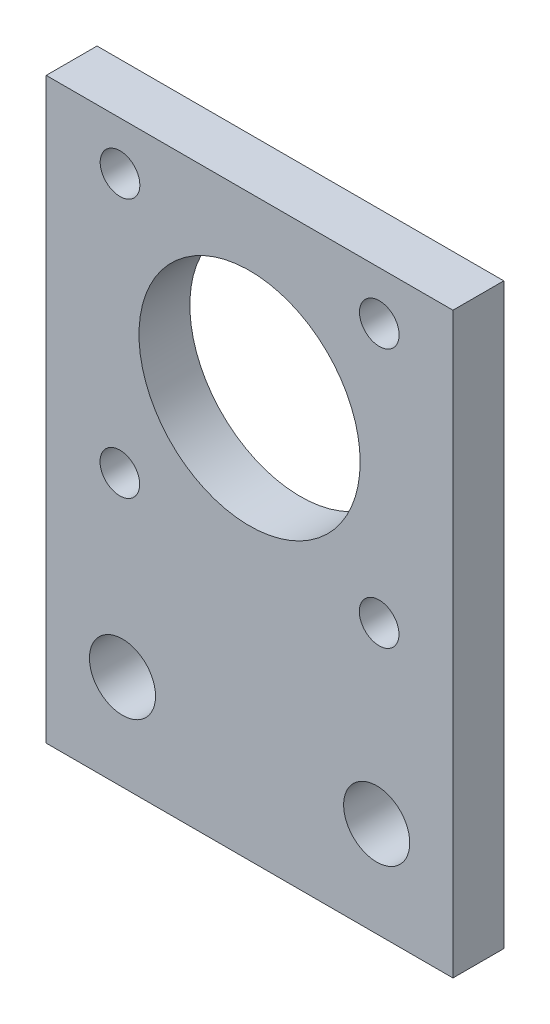
from build123d import *

# Parameters (mm, degrees)
SKETCH1_W           = 40.64
SKETCH1_H           = 19.05
SKETCH1_R           = 3.302
SKETCH1_H_2         = 38.735
SKETCH1_R_2         = 1.9812
SKETCH1_R_3         = 11.049
BOSS_EXTRUDE1_DEPTH = 5.08


with BuildPart() as part:
    # Sketch1 → Boss-Extrude1 (new body)
    with BuildSketch(Plane.XY):
        with Locations((5.46838271, -19.760168498)):
            Rectangle(SKETCH1_W, SKETCH1_H)
        with Locations((-7.23161729, -19.760168498)):
            Circle(SKETCH1_R, mode=Mode.SUBTRACT)
        with Locations((18.16838271, -19.760168498)):
            Circle(SKETCH1_R, mode=Mode.SUBTRACT)
        with Locations((5.46838271, 9.132331502)):
            Rectangle(SKETCH1_W, SKETCH1_H_2)
        with Locations((-7.494416142, -2.225366655)):
            Circle(SKETCH1_R_2, mode=Mode.SUBTRACT)
        with Locations((18.413583858, -2.242964365)):
            Circle(SKETCH1_R_2, mode=Mode.SUBTRACT)
        with Locations((-7.476818437, 23.682627368)):
            Circle(SKETCH1_R_2, mode=Mode.SUBTRACT)
        with Locations((5.46838271, 10.719831502)):
            Circle(SKETCH1_R_3, mode=Mode.SUBTRACT)
        with Locations((18.431181563, 23.665029659)):
            Circle(SKETCH1_R_2, mode=Mode.SUBTRACT)
    extrude(amount=BOSS_EXTRUDE1_DEPTH)


solid = part.part
